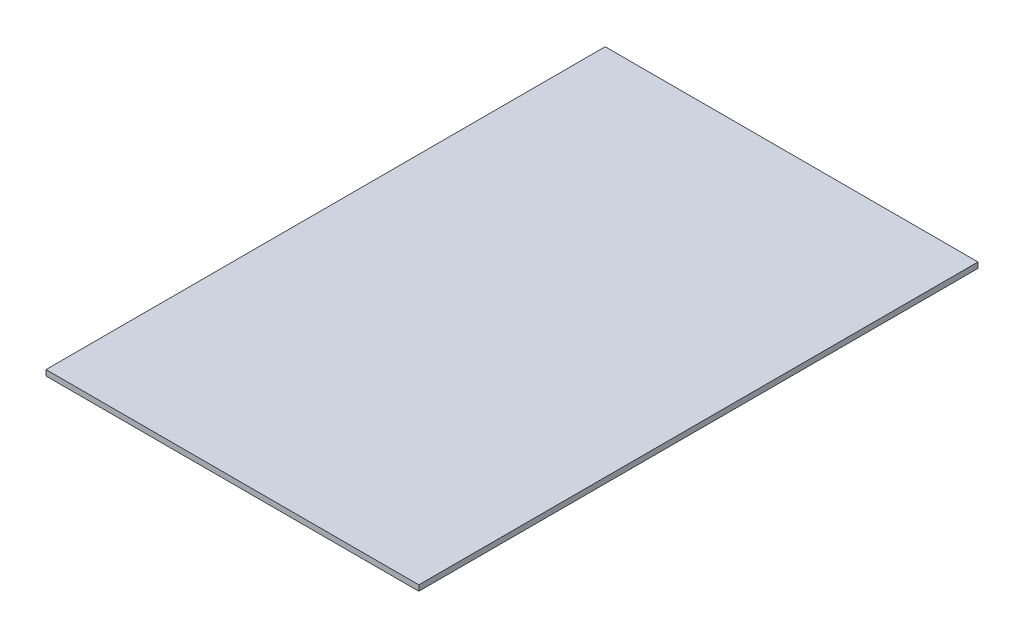
from build123d import *

# Parameters (mm, degrees)
SKETCH1_W           = 200
SKETCH1_H           = 300
BOSS_EXTRUDE1_DEPTH = 3


with BuildPart() as part:
    # Sketch1 → Boss-Extrude1 (new body)
    with BuildSketch(Plane(origin=(0, 0, 0), x_dir=(1, 0, 0), z_dir=(0, 1, 0))):
        Rectangle(SKETCH1_W, SKETCH1_H)
    extrude(amount=BOSS_EXTRUDE1_DEPTH)


solid = part.part
